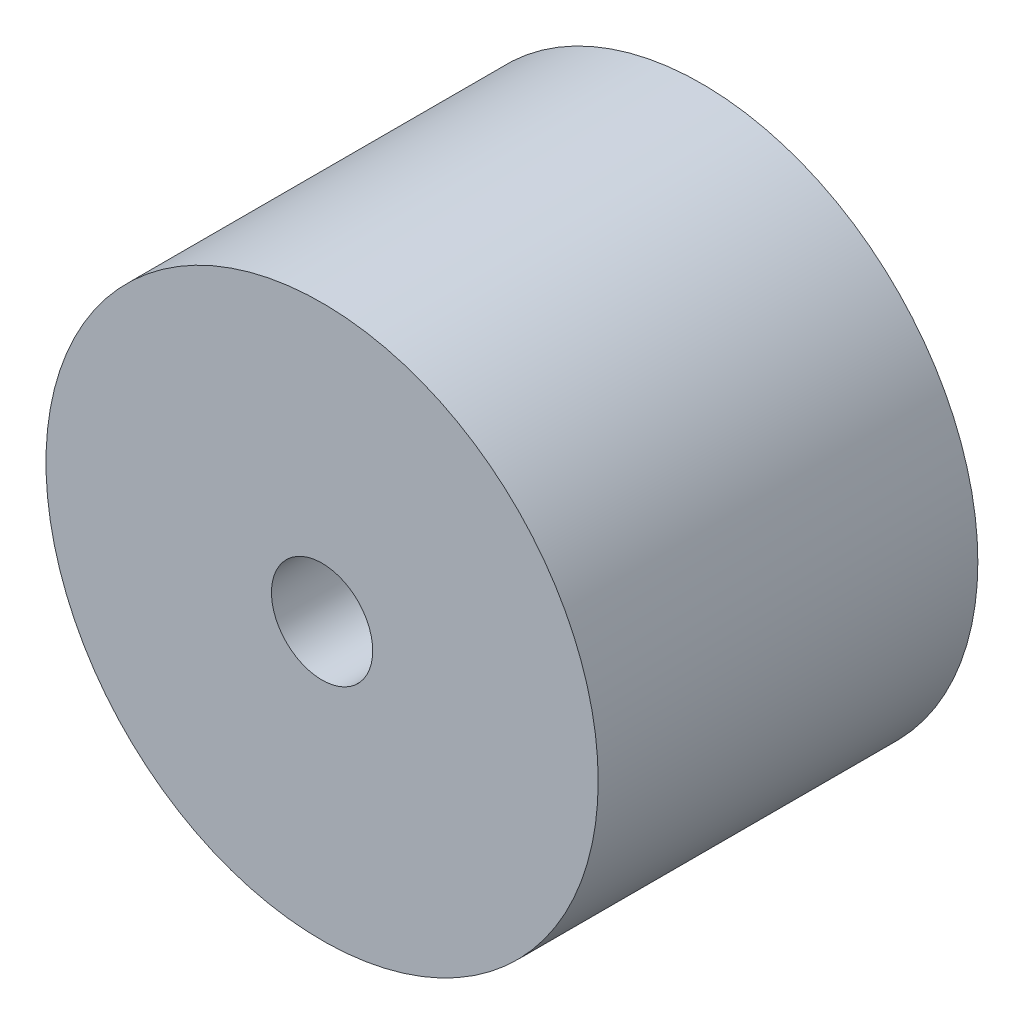
from build123d import *

# Parameters (mm, degrees)
SKETCH_1_R      = 21.818181818
SKETCH_1_R_2    = 4
EXTRUDE_1_DEPTH = 30


with BuildPart() as part:
    # 草图1 → 凸台-拉伸1 (new body)
    with BuildSketch(Plane.XY):
        Circle(SKETCH_1_R)
        Circle(SKETCH_1_R_2, mode=Mode.SUBTRACT)
    extrude(amount=EXTRUDE_1_DEPTH)


solid = part.part
